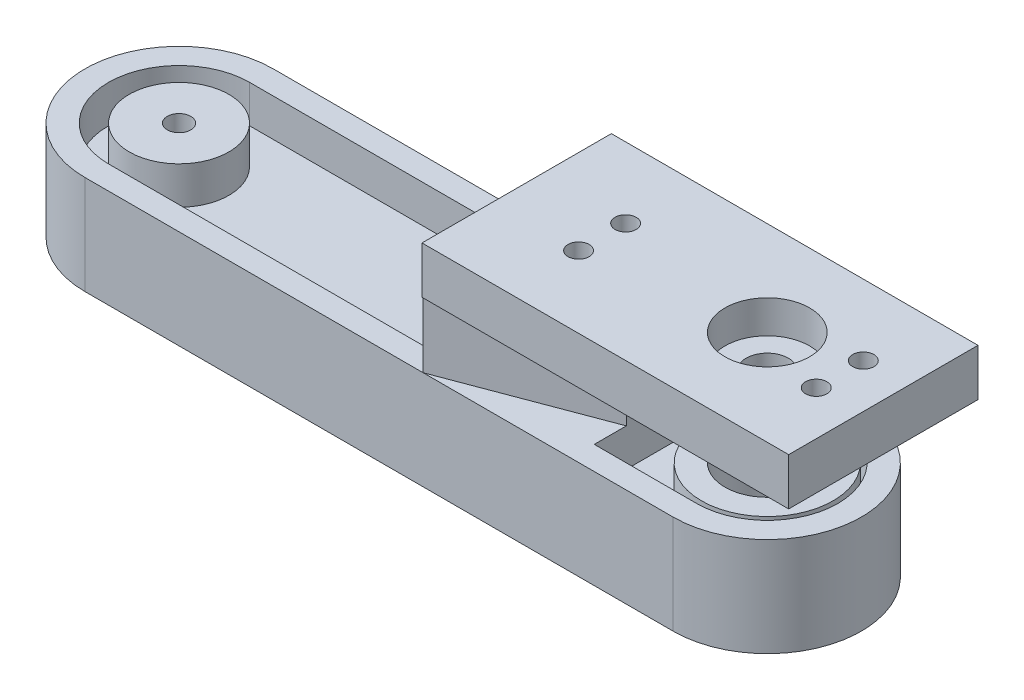
from build123d import *
from build123d.topology import SkipClean

# Parameters (mm, degrees)
BOSS_EXTRUDE1_DEPTH      = 25
SKETCH4_R                = 2.5
CUT_EXTRUDE1_DEPTH       = 101.40542814
CUT_EXTRUDE2_DEPTH       = 10
CUT_EXTRUDE2_DEPTH_BACK  = 101.40542814
CUT_EXTRUDE3_START       = -10
CUT_EXTRUDE3_DEPTH       = 10
SKETCH8_R                = 9
CUT_EXTRUDE5_DEPTH       = 99.393343271
CUT_EXTRUDE6_REACH       = 102.405
BOSS_EXTRUDE3_DEPTH      = 8
BOSS_EXTRUDE3_DEPTH_BACK = 14
SKETCH11_R               = 14
SKETCH11_R_2             = 9
BOSS_EXTRUDE4_DEPTH      = 8
BOSS_EXTRUDE4_DEPTH_BACK = 14
SKETCH9_R                = 10.595859712
SKETCH12_R               = 2.5
CUT_EXTRUDE7_DEPTH       = 89.217061842
SKETCH13_W               = 193.888130969
SKETCH13_H               = 72.528835421
CUT_EXTRUDE8_DEPTH       = 2
SKETCH14_W               = 198.779610567
SKETCH14_H               = 62.99888379
CUT_EXTRUDE9_DEPTH       = 2
SKETCH15_W               = 31.372938112
SKETCH15_H               = 40
BOSS_EXTRUDE6_DEPTH      = 22
SKETCH16_W               = 77.912477191
SKETCH16_H               = 40.233640204
BOSS_EXTRUDE7_DEPTH      = 10
SKETCH17_R               = 9
CUT_EXTRUDE10_DEPTH      = 10
SKETCH18_R               = 2.25
CUT_EXTRUDE11_DEPTH      = 10
CUT_EXTRUDE12_DEPTH      = 14
CUT_EXTRUDE13_DEPTH      = 14
SKETCH21_R               = 9
SKETCH21_R_2             = 4.5
BOSS_EXTRUDE9_DEPTH      = 3


with BuildPart() as part:
    # Sketch1 → Boss-Extrude1 (new body)
    with BuildSketch(Plane(origin=(0, 0, 0), x_dir=(1, 0, 0), z_dir=(0, 1, 0))):
        with BuildLine():
            Line((-62.5, 30), (62.5, 30))
            ThreePointArc((62.5, 30), (92.5, 0), (62.5, -30))
            Line((62.5, -30), (-62.5, -30))
            ThreePointArc((-62.5, -30), (-92.5, 0), (-62.5, 30))
        make_face()
    extrude(amount=BOSS_EXTRUDE1_DEPTH)

    # Sketch4 → Cut-Extrude1 (cut, through all)
    with BuildSketch(Plane(origin=(0, 25, 0), x_dir=(1, 0, 0), z_dir=(0, 1, 0))):
        with Locations((-62.5, 0)):
            Circle(SKETCH4_R)
    extrude(amount=-CUT_EXTRUDE1_DEPTH, mode=Mode.SUBTRACT)

    # Sketch1_3 → Cut-Extrude2 (cut, two sides: drawn at the far end of the back side and taken through both)
    with BuildSketch(Plane(origin=(0, 0, 0), x_dir=(1, 0, 0), z_dir=(0, 1, 0)).offset(-CUT_EXTRUDE2_DEPTH_BACK)):
        with BuildLine():
            Line((-62.5, 15), (62.5, 15))
            ThreePointArc((62.5, 15), (77.5, 0), (62.5, -15))
            Line((62.5, -15), (-62.5, -15))
            ThreePointArc((-62.5, -15), (-77.5, 0), (-62.5, 15))
        make_face()
    extrude(amount=CUT_EXTRUDE2_DEPTH + CUT_EXTRUDE2_DEPTH_BACK, mode=Mode.SUBTRACT)

    # Sketch7 → Cut-Extrude3 (cut)
    with BuildSketch(Plane(origin=(0, 25, 0), x_dir=(1, 0, 0), z_dir=(0, 1, 0)).offset(CUT_EXTRUDE3_START)):
        with BuildLine():
            Line((-62.5, 15), (62.5, 15))
            ThreePointArc((62.5, 15), (77.5, 0), (62.5, -15))
            Line((62.5, -15), (-62.5, -15))
            ThreePointArc((-62.5, -15), (-77.5, 0), (-62.5, 15))
        make_face()
    extrude(amount=CUT_EXTRUDE3_DEPTH, mode=Mode.SUBTRACT)

    # Sketch8 → Cut-Extrude5 (cut, through all)
    with BuildSketch(Plane(origin=(0, 10, 0), x_dir=(-1, 0, 0), z_dir=(0, -1, 0))):
        with Locations((-62.5, 0)):
            Circle(SKETCH8_R)
    extrude(amount=-CUT_EXTRUDE5_DEPTH, mode=Mode.SUBTRACT)

    # Sketch10 → Cut-Extrude6 (cut, up to next)
    with BuildSketch(Plane(origin=(0, 25, 0), x_dir=(1, 0, 0), z_dir=(0, 1, 0)), mode=Mode.PRIVATE) as cut_extrude6_sk1:
        with BuildLine():
            Line((-62.5, -30), (62.5, -30))
            ThreePointArc((62.5, -30), (92.5, 0), (62.5, 30))
            Line((62.5, 30), (-62.5, 30))
            ThreePointArc((-62.5, 30), (-92.5, 0), (-62.5, -30))
        make_face()
        with BuildLine():
            Line((-62.5, 20), (62.5, 20))
            ThreePointArc((62.5, 20), (82.5, 0), (62.5, -20))
            Line((62.5, -20), (-62.5, -20))
            ThreePointArc((-62.5, -20), (-82.5, 0), (-62.5, 20))
        make_face(mode=Mode.SUBTRACT)
    cut_extrude6_tool1 = extrude(cut_extrude6_sk1.sketch, amount=-CUT_EXTRUDE6_REACH, mode=Mode.PRIVATE) & part.part
    add(cut_extrude6_tool1.solids().sort_by_distance((0, 25, 28.055135))[0], mode=Mode.SUBTRACT)

    # Sketch11 → Boss-Extrude3 (add, two sides: drawn at the far end of the back side and taken through both)
    with BuildSketch(Plane(origin=(0, 15, 0), x_dir=(1, 0, 0), z_dir=(0, 1, 0)).offset(-BOSS_EXTRUDE3_DEPTH_BACK)):
        with Locations((62.5, 0)):
            Circle(SKETCH11_R)
        with Locations((62.5, 0)):
            Circle(SKETCH11_R_2, mode=Mode.SUBTRACT)
    extrude(amount=BOSS_EXTRUDE3_DEPTH + BOSS_EXTRUDE3_DEPTH_BACK)

    # Sketch9 → Boss-Extrude4 (add, two sides: drawn at the far end of the back side and taken through both)
    with BuildSketch(Plane(origin=(0, 15, 0), x_dir=(1, 0, 0), z_dir=(0, 1, 0)).offset(-BOSS_EXTRUDE4_DEPTH_BACK)):
        with Locations((-62.5, 0)):
            Circle(SKETCH9_R)
    extrude(amount=BOSS_EXTRUDE4_DEPTH + BOSS_EXTRUDE4_DEPTH_BACK)

    # Sketch12 → Cut-Extrude7 (cut, through all)
    with BuildSketch(Plane.XZ.offset(-1)):
        with Locations((-62.5, 0)):
            Circle(SKETCH12_R)
    extrude(amount=-CUT_EXTRUDE7_DEPTH, mode=Mode.SUBTRACT)

    # Sketch13 → Cut-Extrude8 (cut)
    with BuildSketch(Plane(origin=(0, 25, 0), x_dir=(1, 0, 0), z_dir=(0, 1, 0))):
        with Locations((-4.849311671, -4.672767471)):
            Rectangle(SKETCH13_W, SKETCH13_H)
    extrude(amount=-CUT_EXTRUDE8_DEPTH, mode=Mode.SUBTRACT)

    # Sketch14 → Cut-Extrude9 (cut)
    with BuildSketch(Plane.XZ):
        with Locations((0.126503783, -3.704696323)):
            Rectangle(SKETCH14_W, SKETCH14_H)
    extrude(amount=-CUT_EXTRUDE9_DEPTH, mode=Mode.SUBTRACT)

    # Sketch15 → Boss-Extrude6 (add)
    with BuildSketch(Plane(origin=(0, 15, 0), x_dir=(1, 0, 0), z_dir=(0, 1, 0))):
        with Locations((25.047748977, 0)):
            Rectangle(SKETCH15_W, SKETCH15_H)
    extrude(amount=BOSS_EXTRUDE6_DEPTH)

    # Sketch16 → Boss-Extrude7 (add)
    with SkipClean():  # the faces are left unmerged after this step: merging them gives an invalid solid
        with BuildSketch(Plane(origin=(0, 37, 0), x_dir=(1, 0, 0), z_dir=(0, 1, 0))):
            with Locations((48.317518517, -0.116820102)):
                Rectangle(SKETCH16_W, SKETCH16_H)
        extrude(amount=BOSS_EXTRUDE7_DEPTH)

    # Sketch17 → Cut-Extrude10 (cut)
    with SkipClean():  # the faces are left unmerged after this step: merging them gives an invalid solid
        with BuildSketch(Plane.XZ.offset(-37)):
            with Locations((62.5, 0)):
                Circle(SKETCH17_R)
        extrude(amount=-CUT_EXTRUDE10_DEPTH, mode=Mode.SUBTRACT)

    # Sketch18 → Cut-Extrude11 (cut)
    with SkipClean():  # the faces are left unmerged after this step: merging them gives an invalid solid
        with BuildSketch(Plane(origin=(0, 47, 0), x_dir=(1, 0, 0), z_dir=(0, 1, 0))):
            with Locations((27.4, 5)):
                Circle(SKETCH18_R)
            with Locations((27.4, -5)):
                Circle(SKETCH18_R)
            with Locations((77.9, 5)):
                Circle(SKETCH18_R)
            with Locations((77.9, -5)):
                Circle(SKETCH18_R)
        extrude(amount=-CUT_EXTRUDE11_DEPTH, mode=Mode.SUBTRACT)

    # Sketch19 → Cut-Extrude12 (cut)
    with BuildSketch(Plane(origin=(0, 23, 0), x_dir=(1, 0, 0), z_dir=(0, 1, 0))):
        Polygon((62.5, 0), (9.361279921, 20), (62.5, 20), align=None)
    extrude(amount=CUT_EXTRUDE12_DEPTH, mode=Mode.SUBTRACT)

    # Sketch20 → Cut-Extrude13 (cut)
    with BuildSketch(Plane(origin=(0, 23, 0), x_dir=(1, 0, 0), z_dir=(0, 1, 0))):
        Polygon((62.5, 0), (9.361279921, -20), (62.5, -20.233640204), align=None)
    extrude(amount=CUT_EXTRUDE13_DEPTH, mode=Mode.SUBTRACT)

    # Sketch21 → Boss-Extrude9 (add)
    with BuildSketch(Plane.XZ.offset(-37)):
        with Locations((62.5, 0)):
            Circle(SKETCH21_R)
        with Locations((62.5, 0)):
            Circle(SKETCH21_R_2, mode=Mode.SUBTRACT)
    extrude(amount=-BOSS_EXTRUDE9_DEPTH)


solid = part.part
